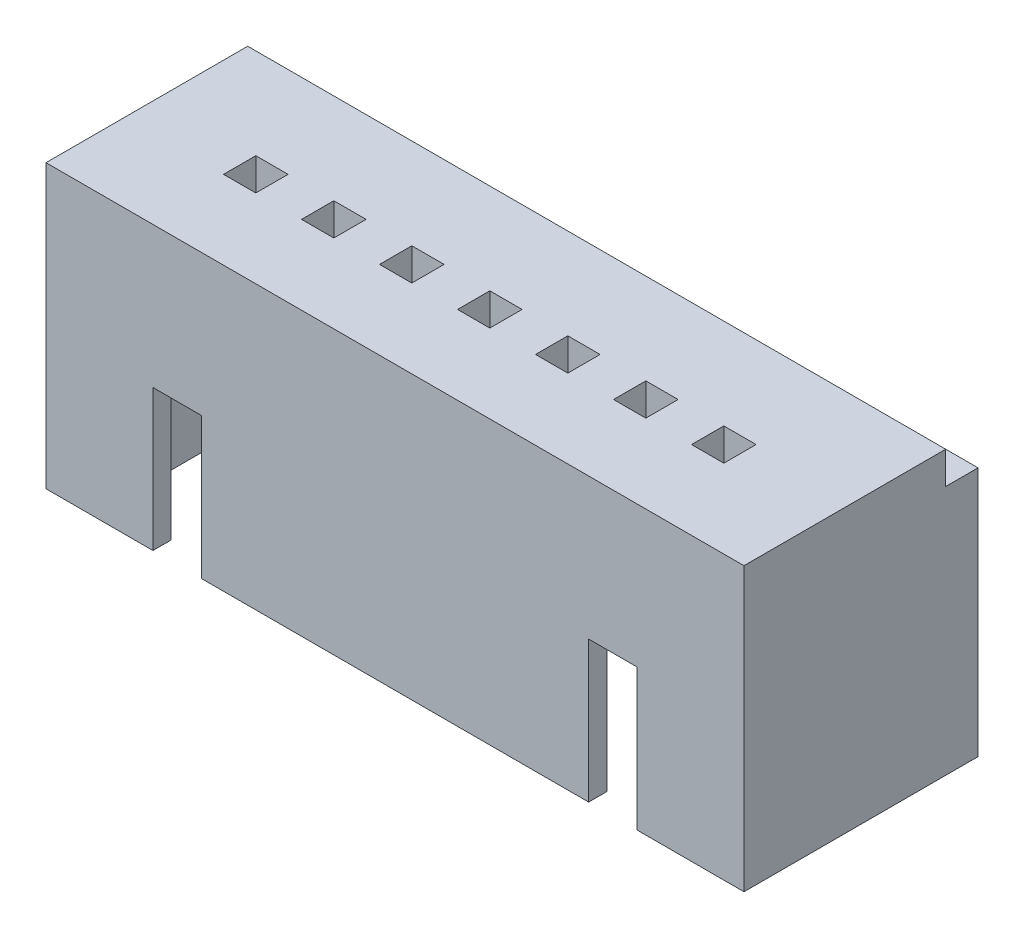
from build123d import *

# Parameters (mm, degrees)
SKETCH1_W           = 17.3
SKETCH1_H           = 5.8
BOSS_EXTRUDE1_DEPTH = 7
SKETCH3_W           = 15
SKETCH3_H           = 4.9
CUT_EXTRUDE1_DEPTH  = 5
SKETCH4_W           = 1.2
SKETCH4_H           = 3.5
CUT_EXTRUDE2_DEPTH  = 4
SKETCH5_W           = 17.3
SKETCH5_H           = 0.8
CUT_EXTRUDE3_DEPTH  = 0.8
SKETCH6_W           = 0.8
SKETCH6_H           = 0.8
CUT_EXTRUDE4_DEPTH  = 10
SKETCH7_W           = 15
SKETCH7_H           = 1
CUT_EXTRUDE5_DEPTH  = 0.3


with BuildPart() as part:
    # Sketch1 → Boss-Extrude1 (new body)
    with BuildSketch(Plane(origin=(0, 0, 0), x_dir=(1, 0, 0), z_dir=(0, 1, 0))):
        Rectangle(SKETCH1_W, SKETCH1_H)
    extrude(amount=BOSS_EXTRUDE1_DEPTH)

    # Sketch3 → Cut-Extrude1 (cut)
    with BuildSketch(Plane.XZ):
        Rectangle(SKETCH3_W, SKETCH3_H)
    extrude(amount=-CUT_EXTRUDE1_DEPTH, mode=Mode.SUBTRACT)

    # Sketch4 → Cut-Extrude2 (cut)
    with BuildSketch(Plane.XY.offset(2.9)):
        with Locations((-5.4, 1.75)):
            Rectangle(SKETCH4_W, SKETCH4_H)
        with Locations((5.4, 1.75)):
            Rectangle(SKETCH4_W, SKETCH4_H)
    extrude(amount=-CUT_EXTRUDE2_DEPTH, mode=Mode.SUBTRACT)

    # Sketch5 → Cut-Extrude3 (cut)
    with BuildSketch(Plane(origin=(0, 7, 0), x_dir=(1, 0, 0), z_dir=(0, 1, 0))):
        with Locations((0, 2.5)):
            Rectangle(SKETCH5_W, SKETCH5_H)
    extrude(amount=-CUT_EXTRUDE3_DEPTH, mode=Mode.SUBTRACT)

    # Sketch6 → Cut-Extrude4 (cut)
    with BuildSketch(Plane(origin=(0, 7, 0), x_dir=(1, 0, 0), z_dir=(0, 1, 0))):
        with Locations((5.8, -0.55)):
            Rectangle(SKETCH6_W, SKETCH6_H)
        with Locations((3.866666667, -0.55)):
            Rectangle(SKETCH6_W, SKETCH6_H)
        with Locations((1.933333333, -0.55)):
            Rectangle(SKETCH6_W, SKETCH6_H)
        with Locations((0, -0.55)):
            Rectangle(SKETCH6_W, SKETCH6_H)
        with Locations((-1.933333333, -0.55)):
            Rectangle(SKETCH6_W, SKETCH6_H)
        with Locations((-3.866666667, -0.55)):
            Rectangle(SKETCH6_W, SKETCH6_H)
        with Locations((-5.8, -0.55)):
            Rectangle(SKETCH6_W, SKETCH6_H)
    extrude(amount=-CUT_EXTRUDE4_DEPTH, mode=Mode.SUBTRACT)

    # Sketch7 → Cut-Extrude5 (cut)
    with BuildSketch(Plane.XZ.offset(-5)):
        with Locations((0, -1.95)):
            Rectangle(SKETCH7_W, SKETCH7_H)
    extrude(amount=-CUT_EXTRUDE5_DEPTH, mode=Mode.SUBTRACT)


solid = part.part
